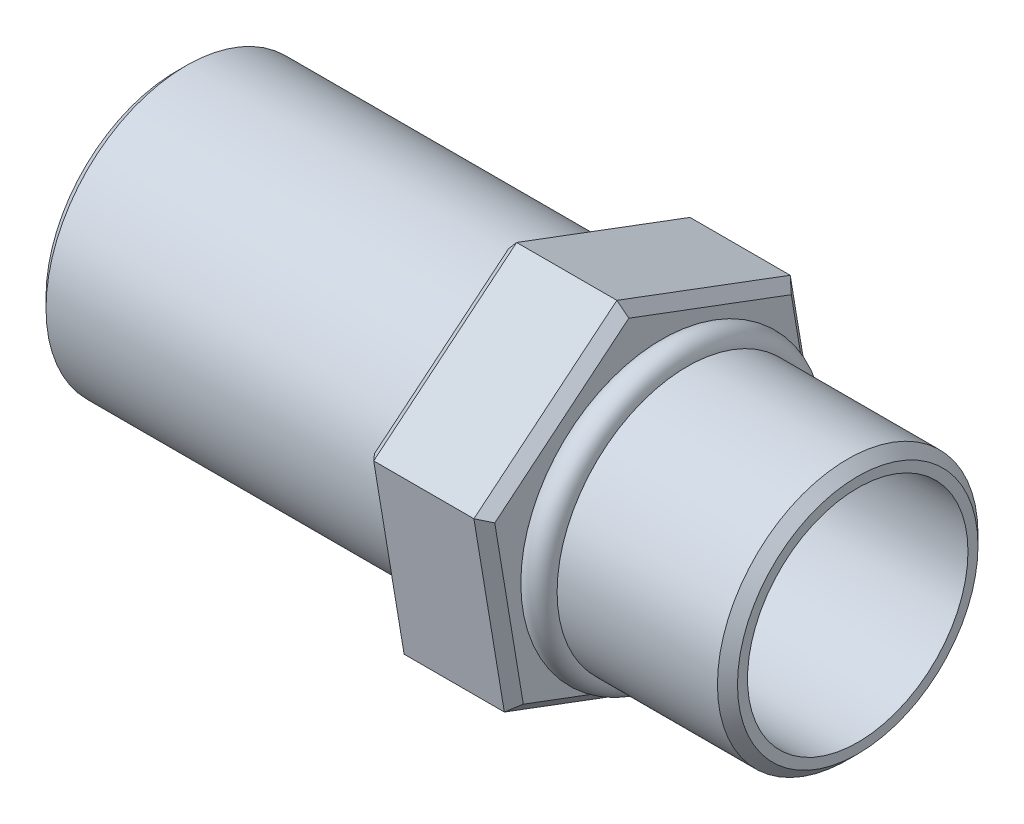
from build123d import *

# Parameters (mm, degrees)
ESQUISSE1_R             = 0.65
BOSS_EXTRU_1_DEPTH      = 1
BOSS_EXTRU_2_DEPTH      = 0.6
ESQUISSE4_R             = 0.7
BOSS_EXTRU_3_DEPTH      = 1.8
CHANFREIN1_SIZE         = 0.05
CHANFREIN2_SIZE         = 0.05
ESQUISSE5_R             = 0.575
ENL_V_MAT_EXTRU_1_DEPTH = 2.4
ESQUISSE6_R             = 0.55
ENL_V_MAT_EXTRU_2_DEPTH = 2.4
CHANFREIN3_SIZE         = 0.05
CHANFREIN4_SIZE         = 0.05
CHANFREIN5_SIZE         = 0.01
ESQUISSE7_R             = 0.075
BOSS_EXTRU_4_DEPTH      = 1.5
ECHELLE1_SCALE          = 10


with BuildPart() as part:
    # Esquisse1 → Boss.-Extru.1 (new body)
    with BuildSketch(Plane(origin=(0, 0, 0), x_dir=(0, 0, -1), z_dir=(1, 0, 0))):
        Circle(ESQUISSE1_R)
    extrude(amount=BOSS_EXTRU_1_DEPTH)

    # Esquisse2 → Révolution1 (revolve)
    with BuildSketch(Plane.XY):
        with BuildLine():
            Line((0, 0.65), (0.15, 0.65))
            ThreePointArc((0.15, 0.65), (0.075, 0.725), (0, 0.65))
        make_face()
    revolve(axis=Axis((1, 0, 0), (-1, 0, 0)))

    # Esquisse3 → Boss.-Extru.2 (add)
    with BuildSketch(Plane.ZY):
        Polygon((0.713221279, -0.587067918), (0.86502637, 0.324133787), (0.151805091, 0.911201705), (-0.713221279, 0.587067918), (-0.86502637, -0.324133787), (-0.151805091, -0.911201705), align=None)
    extrude(amount=BOSS_EXTRU_2_DEPTH)

    # Esquisse4 → Boss.-Extru.3 (add)
    with BuildSketch(Plane.ZY.offset(0.6)):
        Circle(ESQUISSE4_R)
    extrude(amount=BOSS_EXTRU_3_DEPTH)

    # Chanfrein1
    chanfrein1_edges = [part.edges().sort_by_distance(p)[0] for p in [
        (-0.6, -0.749134812, 0.280708094),
        (-0.6, -0.131467065, 0.789123825),
        (-0.6, 0.617667746, 0.508415731),
        (-0.6, 0.749134812, -0.280708094),
        (-0.6, 0.131467065, -0.789123825),
        (-0.6, -0.617667746, -0.508415731),
    ]]
    chamfer(chanfrein1_edges, length=CHANFREIN1_SIZE)

    # Chanfrein2
    chanfrein2_edges = [part.edges().sort_by_distance(p)[0] for p in [
        (0, 0.749134812, -0.280708094),
        (0, 0.131467065, -0.789123825),
        (0, -0.617667746, -0.508415731),
        (0, -0.749134812, 0.280708094),
        (0, -0.131467065, 0.789123825),
        (0, 0.617667746, 0.508415731),
    ]]
    chamfer(chanfrein2_edges, length=CHANFREIN2_SIZE)

    # Esquisse5 → Enlèv. mat.-Extru.1 (cut)
    with BuildSketch(Plane.ZY.offset(2.4)):
        Circle(ESQUISSE5_R)
    extrude(amount=-ENL_V_MAT_EXTRU_1_DEPTH, mode=Mode.SUBTRACT)

    # Esquisse6 → Enlèv. mat.-Extru.2 (cut)
    with BuildSketch(Plane(origin=(1, 0, 0), x_dir=(0, 0, -1), z_dir=(1, 0, 0))):
        Circle(ESQUISSE6_R)
    extrude(amount=-ENL_V_MAT_EXTRU_2_DEPTH, mode=Mode.SUBTRACT)

    # Chanfrein3
    chanfrein3_edges = [part.edges().sort_by_distance(p)[0] for p in [
        (1, 0, 0.65),
    ]]
    chamfer(chanfrein3_edges, length=CHANFREIN3_SIZE)

    # Chanfrein4
    chanfrein4_edges = [part.edges().sort_by_distance(p)[0] for p in [
        (-2.4, 0, -0.7),
    ]]
    chamfer(chanfrein4_edges, length=CHANFREIN4_SIZE)

    # Chanfrein5
    chanfrein5_edges = [part.edges().sort_by_distance(p)[0] for p in [
        (-0.6, 0, -0.7),
    ]]
    chamfer(chanfrein5_edges, length=CHANFREIN5_SIZE)

    # Esquisse7 → Boss.-Extru.4 (add)
    with BuildSketch(Plane(origin=(0, 0.617667746, 0.508415731), x_dir=(1, 0, 0), z_dir=(0, 0.772084683, 0.635519663))):
        with Locations((-0.3, 0)):
            Circle(ESQUISSE7_R)
    extrude(amount=-BOSS_EXTRU_4_DEPTH)


with BuildPart() as part_1:
    # Echelle1: scaled about (0, 0, 0)
    add(part.part.scale(ECHELLE1_SCALE))


solid = part_1.part
